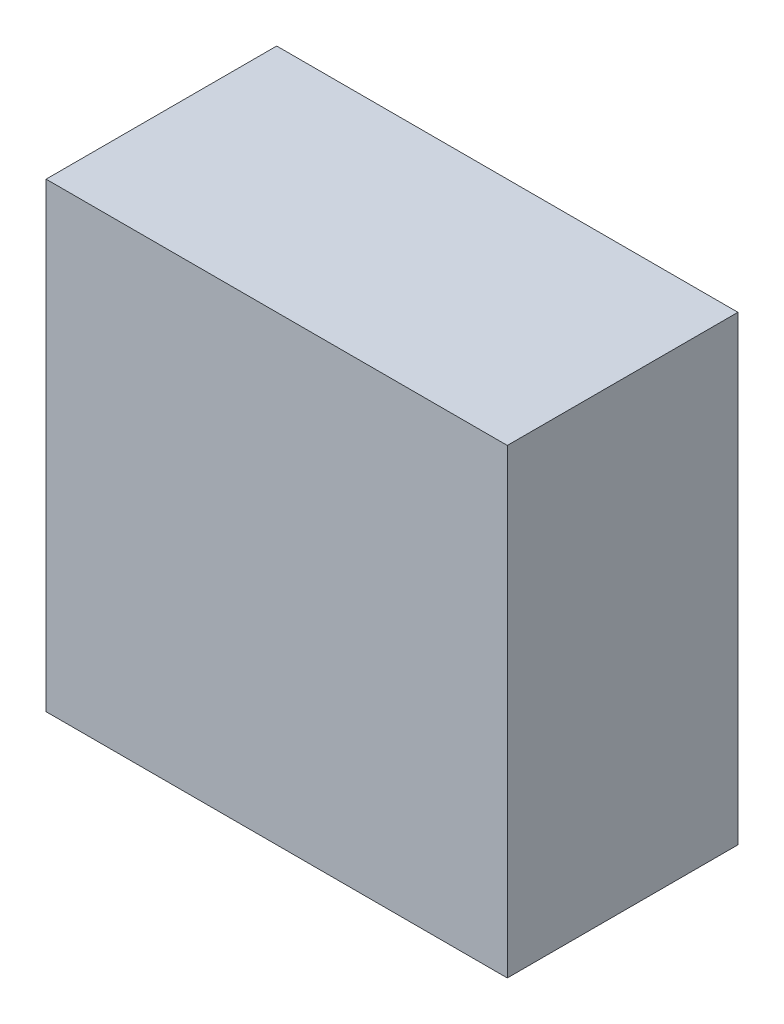
from build123d import *

# Parameters (mm, degrees)
ESQUISSE1_W        = 400
ESQUISSE1_H        = 200
BOSS_EXTRU_1_DEPTH = 400


with BuildPart() as part:
    # Esquisse1 → Boss.-Extru.1 (new body)
    with BuildSketch(Plane(origin=(0, 0, 0), x_dir=(1, 0, 0), z_dir=(0, 1, 0))):
        Rectangle(ESQUISSE1_W, ESQUISSE1_H)
    extrude(amount=BOSS_EXTRU_1_DEPTH)


solid = part.part
